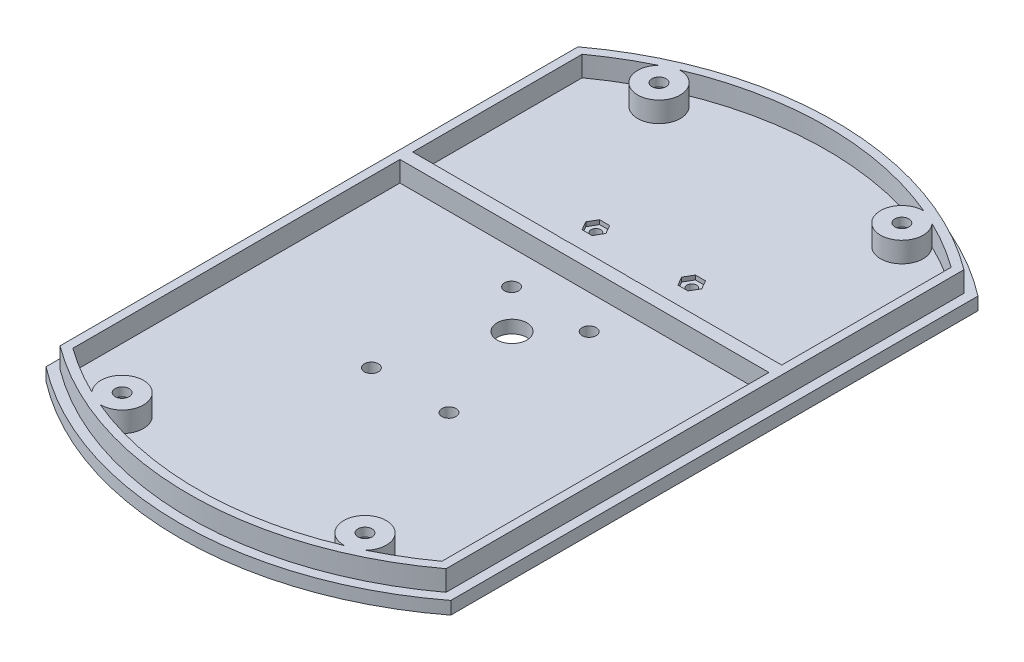
from build123d import *

# Parameters (mm, degrees)
SKETCH_1_R               = 1.65
EXTRUDE_1_DEPTH          = 3
SKETCH_2_R               = 1.65
EXTRUDE_2_DEPTH          = 4.8
SKETCH_7_R               = 3.5
SKETCH_7_R_2             = 1.65
CUT_EXTRUDE_1_DEPTH      = 4
SKETCH_8_R               = 3.25
CUT_EXTRUDE_2_DEPTH      = 5.8
SKETCH_9_W               = 86.6
SKETCH_9_H               = 3
EXTRUDE_3_DEPTH          = 4.8
SKETCH_11_R              = 1.15
CUT_EXTRUDE_3_DEPTH      = 8.8
CUT_EXTRUDE_4_DEPTH      = 5.8
CUT_EXTRUDE_4_DEPTH_BACK = 1


with BuildPart() as part:
    # 草图1 → 凸台-拉伸1 (new body)
    with BuildSketch(Plane(origin=(0, 0, 0), x_dir=(1, 0, 0), z_dir=(0, 1, 0))):
        with BuildLine():
            Line((-47.5, 61.868812822), (-47.5, -61.868812822))
            ThreePointArc((-47.5, -61.868812822), (0, -78), (47.5, -61.868812822))
            Line((47.5, -61.868812822), (47.5, 61.868812822))
            ThreePointArc((47.5, 61.868812822), (0, 78), (-47.5, 61.868812822))
        make_face()
        with Locations((-28.5, 63)):
            Circle(SKETCH_1_R, mode=Mode.SUBTRACT)
        with Locations((28.5, 63)):
            Circle(SKETCH_1_R, mode=Mode.SUBTRACT)
        with Locations((28.5, -63)):
            Circle(SKETCH_1_R, mode=Mode.SUBTRACT)
        with Locations((-28.5, -63)):
            Circle(SKETCH_1_R, mode=Mode.SUBTRACT)
    extrude(amount=EXTRUDE_1_DEPTH)

    # 草图2 → 凸台-拉伸2 (add)
    with BuildSketch(Plane(origin=(0, 3, 0), x_dir=(1, 0, 0), z_dir=(0, 1, 0))):
        with BuildLine():
            Line((-45.3, 60.774583503), (-45.3, -60.774583503))
            ThreePointArc((-45.3, -60.774583503), (0, -75.8), (45.3, -60.774583503))
            Line((45.3, -60.774583503), (45.3, 60.774583503))
            ThreePointArc((45.3, 60.774583503), (0, 75.8), (-45.3, 60.774583503))
        make_face()
        with Locations((-28.5, -63)):
            Circle(SKETCH_2_R, mode=Mode.SUBTRACT)
        with Locations((28.5, -63)):
            Circle(SKETCH_2_R, mode=Mode.SUBTRACT)
        with Locations((28.5, 63)):
            Circle(SKETCH_2_R, mode=Mode.SUBTRACT)
        with Locations((-28.5, 63)):
            Circle(SKETCH_2_R, mode=Mode.SUBTRACT)
        with BuildLine():
            Line((-43.3, 59.762446402), (-43.3, -59.762446402))
            ThreePointArc((-43.3, -59.762446402), (-37.862237267, -63.347383443), (-32.129574495, -66.438922649))
            ThreePointArc((-32.129574495, -66.438922649), (-26.439160651, -58.444460386), (-28.686460015, -67.996522057))
            ThreePointArc((-28.686460015, -67.996522057), (0, -73.8), (28.686460015, -67.996522057))
            ThreePointArc((28.686460015, -67.996522057), (26.439160651, -58.444460386), (32.129574495, -66.438922649))
            ThreePointArc((32.129574495, -66.438922649), (37.862237267, -63.347383443), (43.3, -59.762446402))
            Line((43.3, -59.762446402), (43.3, 59.762446402))
            ThreePointArc((43.3, 59.762446402), (37.862237267, 63.347383443), (32.129574495, 66.438922649))
            ThreePointArc((32.129574495, 66.438922649), (26.439160651, 58.444460386), (28.686460015, 67.996522057))
            ThreePointArc((28.686460015, 67.996522057), (0, 73.8), (-28.686460015, 67.996522057))
            ThreePointArc((-28.686460015, 67.996522057), (-26.439160651, 58.444460386), (-32.129574495, 66.438922649))
            ThreePointArc((-32.129574495, 66.438922649), (-37.862237267, 63.347383443), (-43.3, 59.762446402))
        make_face(mode=Mode.SUBTRACT)
    extrude(amount=EXTRUDE_2_DEPTH)

    # 草图7 → 切除-拉伸1 (cut, through all)
    with BuildSketch(Plane(origin=(0, 3, 0), x_dir=(1, 0, 0), z_dir=(0, 1, 0))):
        Circle(SKETCH_7_R)
        with Locations((9.1, 9)):
            Circle(SKETCH_7_R_2)
        with Locations((-9.1, 9)):
            Circle(SKETCH_7_R_2)
        with Locations((-9.1, -23.9)):
            Circle(SKETCH_7_R_2)
        with Locations((9.1, -23.9)):
            Circle(SKETCH_7_R_2)
    extrude(amount=-CUT_EXTRUDE_1_DEPTH, mode=Mode.SUBTRACT)

    # 草图8 → 切除-拉伸2 (cut)
    with BuildSketch(Plane.XZ):
        with Locations((-28.5, -63)):
            Circle(SKETCH_8_R)
        with Locations((28.5, -63)):
            Circle(SKETCH_8_R)
        with Locations((28.5, 63)):
            Circle(SKETCH_8_R)
        with Locations((-28.5, 63)):
            Circle(SKETCH_8_R)
    extrude(amount=-CUT_EXTRUDE_2_DEPTH, mode=Mode.SUBTRACT)

    # 草图9 → 凸台-拉伸3 (add)
    with BuildSketch(Plane(origin=(0, 3, 0), x_dir=(1, 0, 0), z_dir=(0, 1, 0))):
        with Locations((0, 18.5)):
            Rectangle(SKETCH_9_W, SKETCH_9_H)
    extrude(amount=EXTRUDE_3_DEPTH)

    # 草图11 → 切除-拉伸3 (cut, through all)
    with BuildSketch(Plane.XZ):
        with Locations((-8, -22)):
            Circle(SKETCH_11_R)
        with Locations((-11.249191362, -30.927079897)):
            Circle(SKETCH_11_R)
        with Locations((11.249191362, -30.927079897)):
            Circle(SKETCH_11_R)
        with Locations((8, -22)):
            Circle(SKETCH_11_R)
    extrude(amount=-CUT_EXTRUDE_3_DEPTH, mode=Mode.SUBTRACT)

    # 草图12 → 切除-拉伸4 (cut, two sides)
    with BuildSketch(Plane(origin=(0, 3, 0), x_dir=(1, 0, 0), z_dir=(0, 1, 0))) as cut_extrude_4_sk:
        Polygon((-10.06562331, 32.977079897), (-12.432759413, 32.977079897), (-13.616327465, 30.927079897), (-12.432759413, 28.877079897), (-10.06562331, 28.877079897), (-8.882055258, 30.927079897), align=None)
        Polygon((-5.632863896, 22), (-6.816431948, 24.05), (-9.183568052, 24.05), (-10.367136104, 22), (-9.183568052, 19.95), (-6.816431948, 19.95), align=None)
        Polygon((10.367136104, 22), (9.183568052, 24.05), (6.816431948, 24.05), (5.632863896, 22), (6.816431948, 19.95), (9.183568052, 19.95), align=None)
        Polygon((12.432759413, 32.977079897), (10.06562331, 32.977079897), (8.882055258, 30.927079897), (10.06562331, 28.877079897), (12.432759413, 28.877079897), (13.616327465, 30.927079897), align=None)
    extrude(amount=CUT_EXTRUDE_4_DEPTH, mode=Mode.SUBTRACT)
    extrude(cut_extrude_4_sk.sketch, amount=-CUT_EXTRUDE_4_DEPTH_BACK, mode=Mode.SUBTRACT)


solid = part.part
